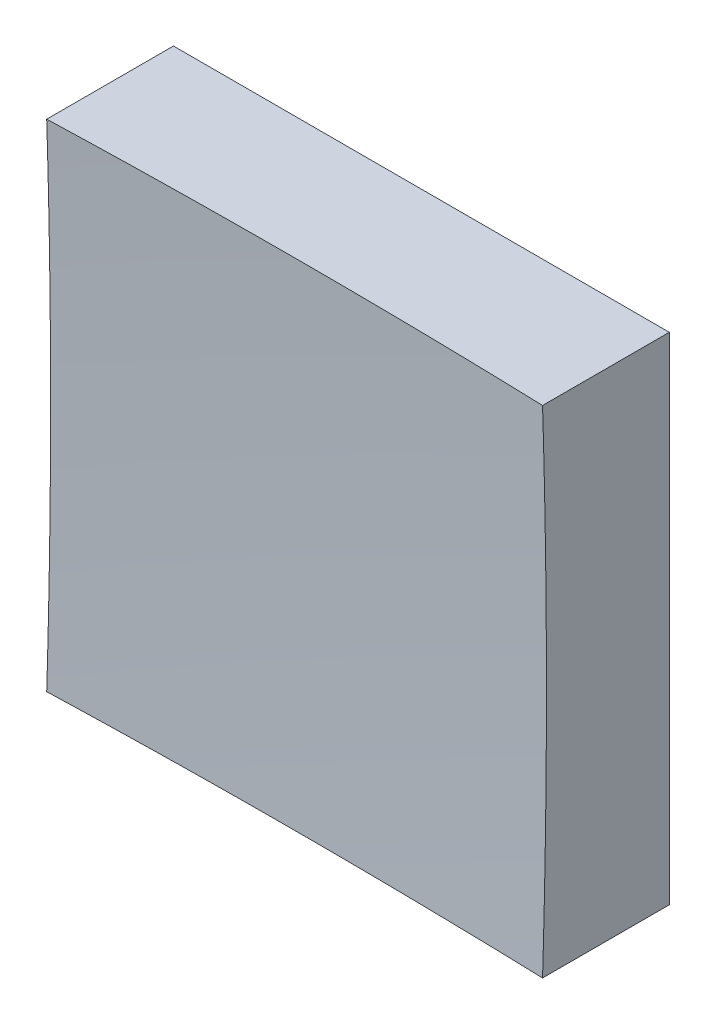
from build123d import *

# Parameters (mm, degrees)
SKETCH_1_W      = 25
SKETCH_1_H      = 25
EXTRUDE_1_DEPTH = 20


with BuildPart() as part:
    # 草图1 → 凸台-拉伸1 (new body)
    with BuildSketch(Plane.XY):
        Rectangle(SKETCH_1_W, SKETCH_1_H)
    extrude(amount=EXTRUDE_1_DEPTH)

    # 草图2 → 切除-旋转2 (revolve, cut)
    with BuildSketch(Plane(origin=(0, 0, 0), x_dir=(1, 0, 0), z_dir=(0, 1, 0))):
        with BuildLine():
            Line((389.938184725, -316.847254146), (0, -316.847254146))
            Line((0, -316.847254146), (0, -6))
            ThreePointArc((0, -6), (249.338025237, -93.221245653), (389.938184725, -316.847254146))
        make_face()
    revolve(axis=Axis((0, 0, 316.847254146), (0, 0, -1)), mode=Mode.SUBTRACT)


solid = part.part
